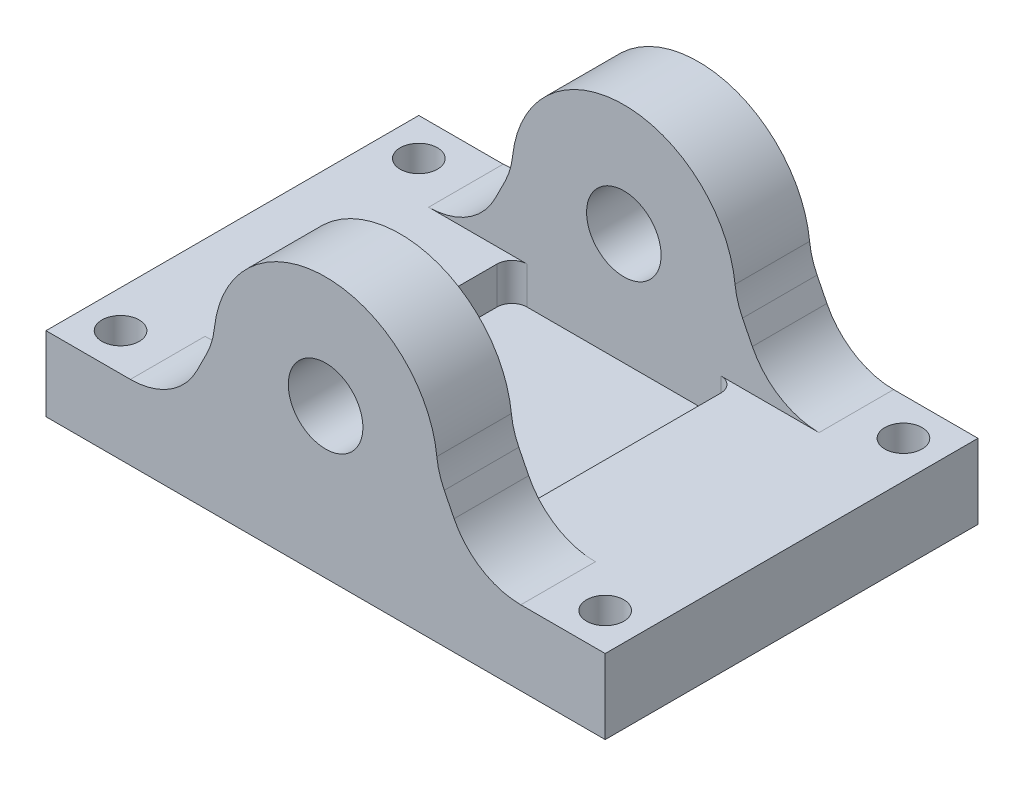
from build123d import *

# Parameters (mm, degrees)
SKETCH1_W               = 75
SKETCH1_H               = 50
BOSS_EXTRUDE1_DEPTH     = 10
BOSS_EXTRUDE2_DEPTH     = 10
FILLET1_R               = 10
SKETCH4_R               = 5
CUT_EXTRUDE1_DEPTH      = 11
FILLET1_OF_MIRROR1_R    = 10
SKETCH5_R               = 2.5
CUT_EXTRUDE2_DEPTH      = 11
MIRROR3_COPY_1_SKETCH_R = 2.5
MIRROR3_COPY_1_DEPTH    = 11
SKETCH6_W               = 30
SKETCH6_H               = 30
CUT_EXTRUDE3_DEPTH      = 5
FILLET2_R               = 2


with BuildPart() as part:
    # Sketch1 → Boss-Extrude1 (new body)
    with BuildSketch(Plane(origin=(0, 0, 0), x_dir=(1, 0, 0), z_dir=(0, 1, 0))):
        with Locations((37.5, 25)):
            Rectangle(SKETCH1_W, SKETCH1_H)
    extrude(amount=BOSS_EXTRUDE1_DEPTH)

    # Sketch2 → Boss-Extrude2 (add)
    with BuildSketch(Plane.XY):
        with BuildLine():
            Line((52.5, 20), (57.5, 10))
            Line((57.5, 10), (17.5, 10))
            Line((17.5, 10), (22.5, 20))
            ThreePointArc((22.5, 20), (37.5, 35), (52.5, 20))
        make_face()
    boss_extrude2 = extrude(amount=-BOSS_EXTRUDE2_DEPTH)

    # Fillet1
    fillet1_edges = [part.edges().sort_by_distance(p)[0] for p in [
        (22.5, 20, -5),
        (52.5, 20, -5),
        (57.5, 10, -5),
        (17.5, 10, -5),
    ]]
    fillet(fillet1_edges, radius=FILLET1_R)

    # Sketch4 → Cut-Extrude1 (cut, through all)
    with BuildSketch(Plane(origin=(0, 0, -10), x_dir=(-1, 0, 0), z_dir=(0, 0, -1))):
        with Locations((-37.5, 20)):
            Circle(SKETCH4_R)
    cut_extrude1 = extrude(amount=-CUT_EXTRUDE1_DEPTH, mode=Mode.SUBTRACT)

    # Mirror1: Boss-Extrude2, Cut-Extrude1 across plane
    add(boss_extrude2.mirror(Plane(origin=(0, 0, -25), x_dir=(1, 0, 0), z_dir=(0, 0, -1))))
    add(cut_extrude1.mirror(Plane(origin=(0, 0, -25), x_dir=(1, 0, 0), z_dir=(0, 0, -1))), mode=Mode.SUBTRACT)

    # Fillet1 of Mirror1
    fillet1_of_mirror1_edges = [part.edges().sort_by_distance(p)[0] for p in [
        (22.5, 20, -45),
        (52.5, 20, -45),
        (57.5, 10, -45),
        (17.5, 10, -45),
    ]]
    fillet(fillet1_of_mirror1_edges, radius=FILLET1_OF_MIRROR1_R)

    # Sketch5 → Cut-Extrude2 (cut, through all)
    with BuildSketch(Plane(origin=(0, 10, 0), x_dir=(1, 0, 0), z_dir=(0, 1, 0))):
        with Locations((5, 5)):
            Circle(SKETCH5_R)
    cut_extrude2 = extrude(amount=-CUT_EXTRUDE2_DEPTH, mode=Mode.SUBTRACT)

    # Mirror2: Cut-Extrude2 across plane
    add(cut_extrude2.mirror(Plane(origin=(0, 0, -25), x_dir=(1, 0, 0), z_dir=(0, 0, -1))), mode=Mode.SUBTRACT)

    # Mirror3: Cut-Extrude2 across plane
    add(cut_extrude2.mirror(Plane(origin=(37.5, 0, 0), x_dir=(0, 0, 1), z_dir=(1, 0, 0))), mode=Mode.SUBTRACT)

    # Mirror3 copy 1 sketch → Mirror3 copy 1 (cut, through all)
    with BuildSketch(Plane(origin=(75, 10, -50), x_dir=(-1, 0, 0), z_dir=(0, 1, 0))):
        with Locations((5, 5)):
            Circle(MIRROR3_COPY_1_SKETCH_R)
    extrude(amount=-MIRROR3_COPY_1_DEPTH, mode=Mode.SUBTRACT)

    # Sketch6 → Cut-Extrude3 (cut)
    with BuildSketch(Plane(origin=(0, 10, 0), x_dir=(1, 0, 0), z_dir=(0, 1, 0))):
        with Locations((37.5, 25)):
            Rectangle(SKETCH6_W, SKETCH6_H)
    extrude(amount=-CUT_EXTRUDE3_DEPTH, mode=Mode.SUBTRACT)

    # Fillet2
    fillet2_edges = [part.edges().sort_by_distance(p)[0] for p in [
        (22.5, 7.5, -10),
        (22.5, 7.5, -40),
        (52.5, 7.5, -40),
        (52.5, 7.5, -10),
    ]]
    fillet(fillet2_edges, radius=FILLET2_R)


solid = part.part
